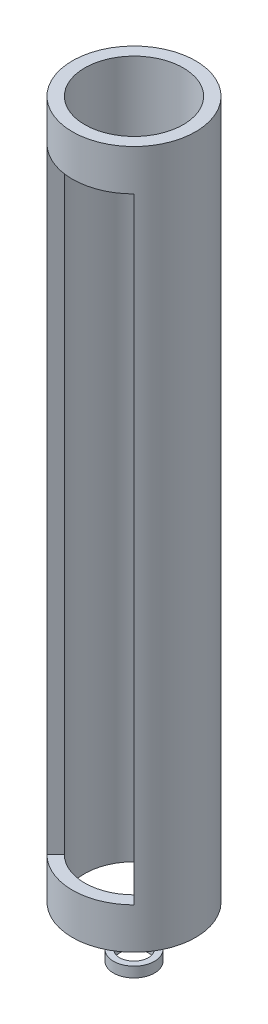
from build123d import *

# Parameters (mm, degrees)
INNER_TUBE_DEPTH     = 150
BOTTOM_EXTRUDE_DEPTH = 10
TOP_START            = 150
TOP_EXTRUDE_DEPTH    = 10
BOSS_EXTRUDE4_START  = -20
SKETCH1_8_R          = 5
SKETCH1_8_R_2        = 3.5
BOSS_EXTRUDE4_DEPTH  = 2.5


with BuildPart() as part:
    # Sketch1 → Inner Tube (new body)
    with BuildSketch(Plane(origin=(0, 0, 0), x_dir=(1, 0, 0), z_dir=(0, 1, 0))):
        with BuildLine():
            Line((-10.606601718, -10.606601718), (-8.485281374, -8.485281374))
            ThreePointArc((-8.485281374, -8.485281374), (-4.592201188, 11.08655439), (12, 0))
            ThreePointArc((12, 0), (11.08655439, -4.592201188), (8.485281374, -8.485281374))
            Line((8.485281374, -8.485281374), (10.606601718, -10.606601718))
            ThreePointArc((10.606601718, -10.606601718), (13.858192988, -5.740251485), (15, 0))
            ThreePointArc((15, 0), (-5.740251485, 13.858192988), (-10.606601718, -10.606601718))
        make_face()
    extrude(amount=INNER_TUBE_DEPTH)

    # Sketch1_3 → Bottom Extrude (add)
    with BuildSketch(Plane(origin=(0, 0, 0), x_dir=(1, 0, 0), z_dir=(0, 1, 0))):
        with BuildLine():
            ThreePointArc((8.485281374, -8.485281374), (0, -12), (-8.485281374, -8.485281374))
            Line((-8.485281374, -8.485281374), (-10.606601718, -10.606601718))
            ThreePointArc((-10.606601718, -10.606601718), (0, -15), (10.606601718, -10.606601718))
            Line((10.606601718, -10.606601718), (8.485281374, -8.485281374))
        make_face()
        with BuildLine():
            Line((-10.606601718, -10.606601718), (-8.485281374, -8.485281374))
            ThreePointArc((-8.485281374, -8.485281374), (-4.592201188, 11.08655439), (12, 0))
            ThreePointArc((12, 0), (11.08655439, -4.592201188), (8.485281374, -8.485281374))
            Line((8.485281374, -8.485281374), (10.606601718, -10.606601718))
            ThreePointArc((10.606601718, -10.606601718), (13.858192988, -5.740251485), (15, 0))
            ThreePointArc((15, 0), (-5.740251485, 13.858192988), (-10.606601718, -10.606601718))
        make_face()
    extrude(amount=-BOTTOM_EXTRUDE_DEPTH)

    # Sketch1_4 → Top Extrude (add)
    with BuildSketch(Plane(origin=(0, 0, 0), x_dir=(1, 0, 0), z_dir=(0, 1, 0)).offset(TOP_START)):
        with BuildLine():
            ThreePointArc((8.485281374, -8.485281374), (0, -12), (-8.485281374, -8.485281374))
            Line((-8.485281374, -8.485281374), (-10.606601718, -10.606601718))
            ThreePointArc((-10.606601718, -10.606601718), (0, -15), (10.606601718, -10.606601718))
            Line((10.606601718, -10.606601718), (8.485281374, -8.485281374))
        make_face()
        with BuildLine():
            Line((-10.606601718, -10.606601718), (-8.485281374, -8.485281374))
            ThreePointArc((-8.485281374, -8.485281374), (-4.592201188, 11.08655439), (12, 0))
            ThreePointArc((12, 0), (11.08655439, -4.592201188), (8.485281374, -8.485281374))
            Line((8.485281374, -8.485281374), (10.606601718, -10.606601718))
            ThreePointArc((10.606601718, -10.606601718), (13.858192988, -5.740251485), (15, 0))
            ThreePointArc((15, 0), (-5.740251485, 13.858192988), (-10.606601718, -10.606601718))
        make_face()
    extrude(amount=TOP_EXTRUDE_DEPTH)


with BuildPart() as body_2:
    # Sketch1_8 → Boss-Extrude4 (new body)
    with BuildSketch(Plane(origin=(0, 0, 0), x_dir=(1, 0, 0), z_dir=(0, 1, 0)).offset(BOSS_EXTRUDE4_START)):
        Circle(SKETCH1_8_R)
        Circle(SKETCH1_8_R_2, mode=Mode.SUBTRACT)
    extrude(amount=-BOSS_EXTRUDE4_DEPTH)


solid = Compound([part.part, body_2.part])
